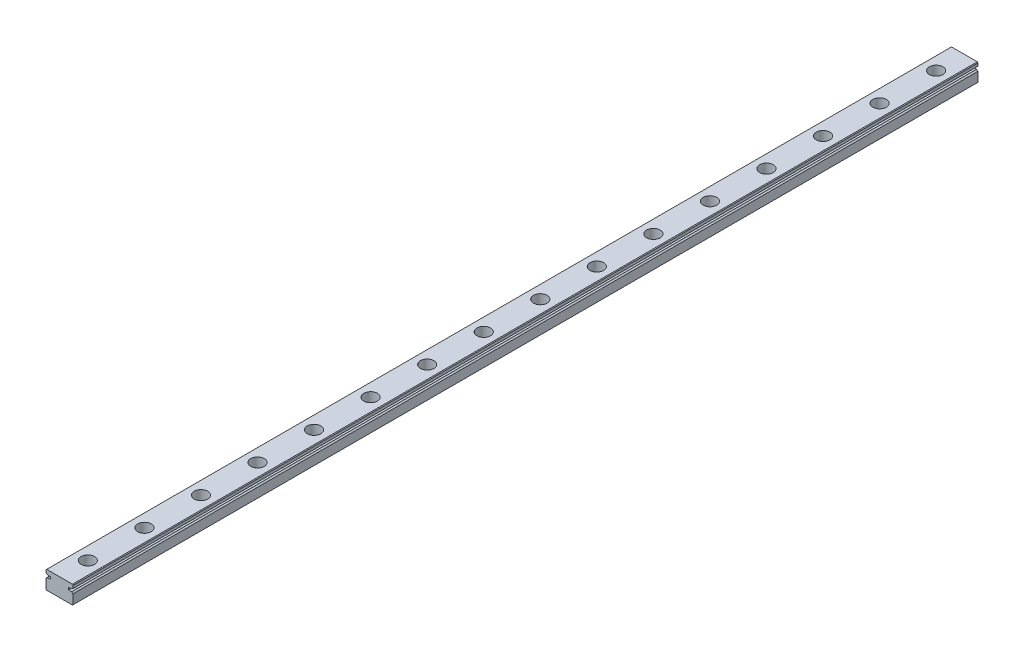
from build123d import *

# Parameters (mm, degrees)
RUNKOPROFIILI_DEPTH = 200
SKETCH2_R           = 3
SKETCH2_R_2         = 1.75
UPOTUS_DEPTH        = 4.5
SKETCH_2_2_R        = 1.75
REIK_2_DEPTH        = 9
PATTERN1_COUNT      = 16
PATTERN1_PITCH      = 25


with BuildPart() as part:
    # Sketch1 → Runkoprofiili (new body, symmetric)
    with BuildSketch(Plane.XY):
        with BuildLine():
            Line((-6, 3.7), (-5.7, 4))
            Line((-5.7, 4), (5.7, 4))
            Line((5.7, 4), (6, 3.7))
            Line((6, 3.7), (6, 2.468245837))
            ThreePointArc((6, 2.468245837), (5.644862234, 2.296120772), (5.383974596, 2))
            Line((5.383974596, 2), (4, 2))
            Line((4, 2), (4, 1))
            Line((4, 1), (5.383974596, 1))
            ThreePointArc((5.383974596, 1), (5.644862234, 0.703879228), (6, 0.531754163))
            Line((6, 0.531754163), (6, -3.7))
            Line((6, -3.7), (5.7, -4))
            Line((5.7, -4), (-5.7, -4))
            Line((-5.7, -4), (-6, -3.7))
            Line((-6, -3.7), (-6, 0.531754163))
            ThreePointArc((-6, 0.531754163), (-5.644862234, 0.703879228), (-5.383974596, 1))
            Line((-5.383974596, 1), (-4, 1))
            Line((-4, 1), (-4, 2))
            Line((-4, 2), (-5.383974596, 2))
            ThreePointArc((-5.383974596, 2), (-5.644862234, 2.296120772), (-6, 2.468245837))
            Line((-6, 2.468245837), (-6, 3.7))
        make_face()
    extrude(amount=RUNKOPROFIILI_DEPTH, both=True)

    # Sketch2 → Upotus (cut)
    with BuildSketch(Plane(origin=(0, 4, 0), x_dir=(1, 0, 0), z_dir=(0, 1, 0))):
        with Locations((0, 187.5)):
            Circle(SKETCH2_R)
        with Locations((0, 187.5)):
            Circle(SKETCH2_R_2, mode=Mode.SUBTRACT)
    upotus = extrude(amount=-UPOTUS_DEPTH, mode=Mode.SUBTRACT)

    # Sketch 2_2 → Reik_2 (cut, through all)
    with BuildSketch(Plane(origin=(0, 4, 0), x_dir=(1, 0, 0), z_dir=(0, 1, 0))):
        with Locations((0, 187.5)):
            Circle(SKETCH_2_2_R)
    reik_2 = extrude(amount=-REIK_2_DEPTH, mode=Mode.SUBTRACT)

    # Pattern1: Upotus, Reik_2 ×16
    with Locations(*[(0, 0, i * PATTERN1_PITCH) for i in range(1, PATTERN1_COUNT)]):
        add(upotus, mode=Mode.SUBTRACT)
        add(reik_2, mode=Mode.SUBTRACT)


solid = part.part
